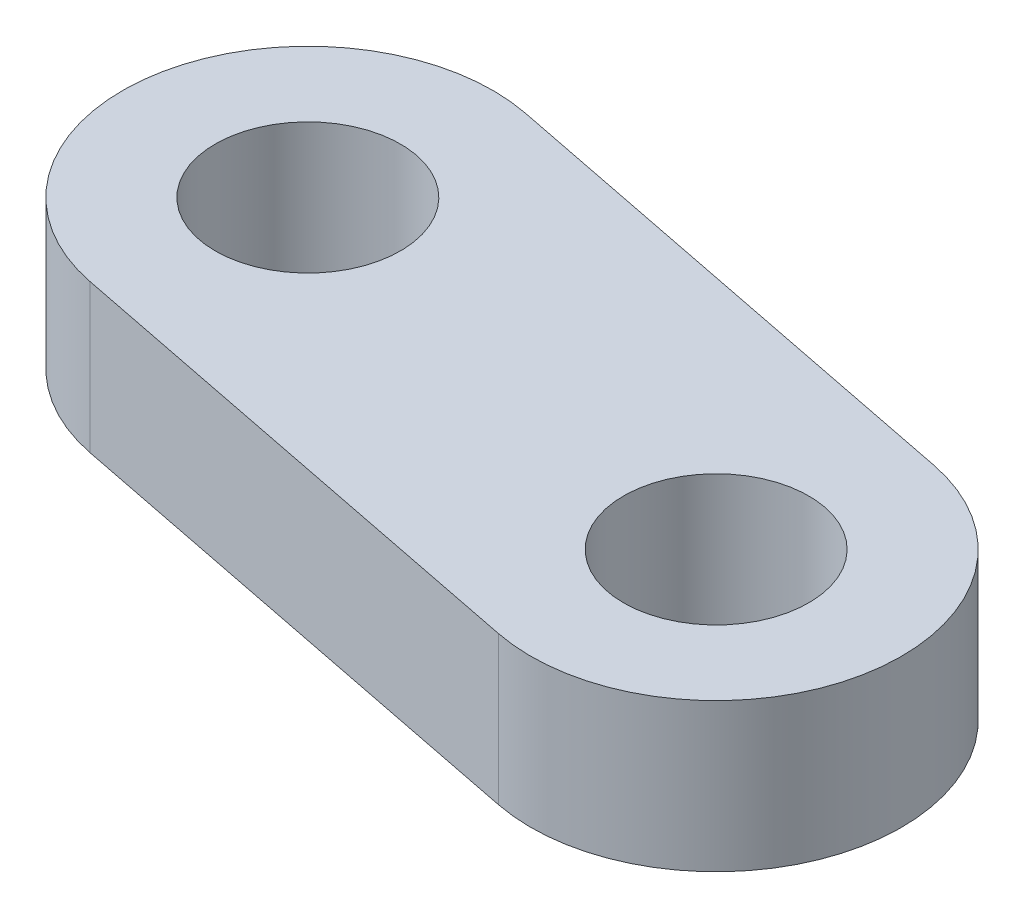
from build123d import *

# Parameters (mm, degrees)
CROQUIS3_R              = 12.5
SALIENTE_EXTRUIR3_DEPTH = 20


with BuildPart() as part:
    # Croquis3 → Saliente-Extruir3 (new body)
    with BuildSketch(Plane(origin=(0, 0, 0), x_dir=(1, 0, 0), z_dir=(0, 1, 0))):
        with BuildLine():
            Line((4.848304654, 24.525373432), (73.519350264, 10.950120401))
            ThreePointArc((73.519350264, 10.950120401), (93.196419042, -18.423557685), (63.822740956, -38.100626463))
            Line((63.822740956, -38.100626463), (-4.848304654, -24.525373432))
            ThreePointArc((-4.848304654, -24.525373432), (-24.525373432, 4.848304654), (4.848304654, 24.525373432))
        make_face()
        Circle(CROQUIS3_R, mode=Mode.SUBTRACT)
        with Locations((68.67104561, -13.575253031)):
            Circle(CROQUIS3_R, mode=Mode.SUBTRACT)
    extrude(amount=SALIENTE_EXTRUIR3_DEPTH)


solid = part.part
